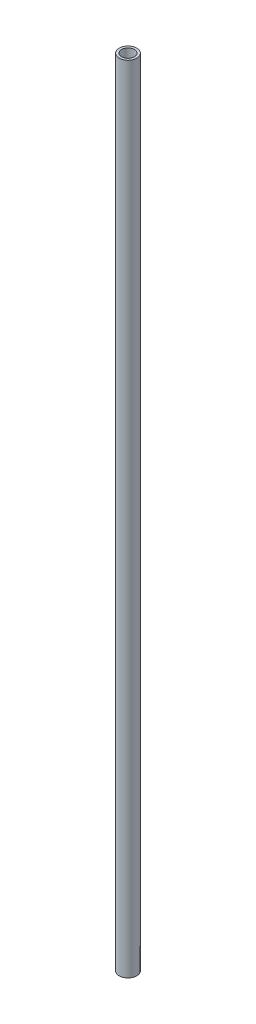
from build123d import *

# Parameters (mm, degrees)
SKETCH1_R           = 4.975
SKETCH1_R_2         = 3.625
BOSS_EXTRUDE1_DEPTH = 452


with BuildPart() as part:
    # Sketch1 → Boss-Extrude1 (new body)
    with BuildSketch(Plane(origin=(0, 0, 0), x_dir=(1, 0, 0), z_dir=(0, 1, 0))):
        Circle(SKETCH1_R)
        Circle(SKETCH1_R_2, mode=Mode.SUBTRACT)
    extrude(amount=BOSS_EXTRUDE1_DEPTH)


solid = part.part
